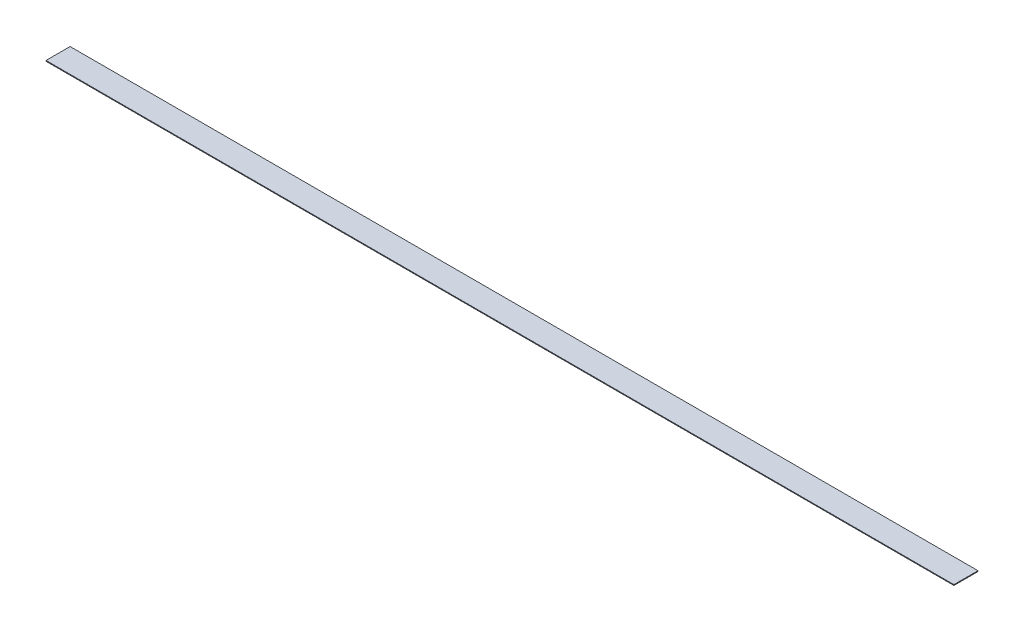
from build123d import *

# Parameters (mm, degrees)
SKETCH1_W           = 1914.525
SKETCH1_H           = 50.8
BOSS_EXTRUDE1_DEPTH = 1.5875


with BuildPart() as part:
    # Sketch1 → Boss-Extrude1 (new body)
    with BuildSketch(Plane(origin=(0, 0, 0), x_dir=(1, 0, 0), z_dir=(0, 1, 0))):
        with Locations((957.2625, 25.4)):
            Rectangle(SKETCH1_W, SKETCH1_H)
    extrude(amount=BOSS_EXTRUDE1_DEPTH)


solid = part.part
